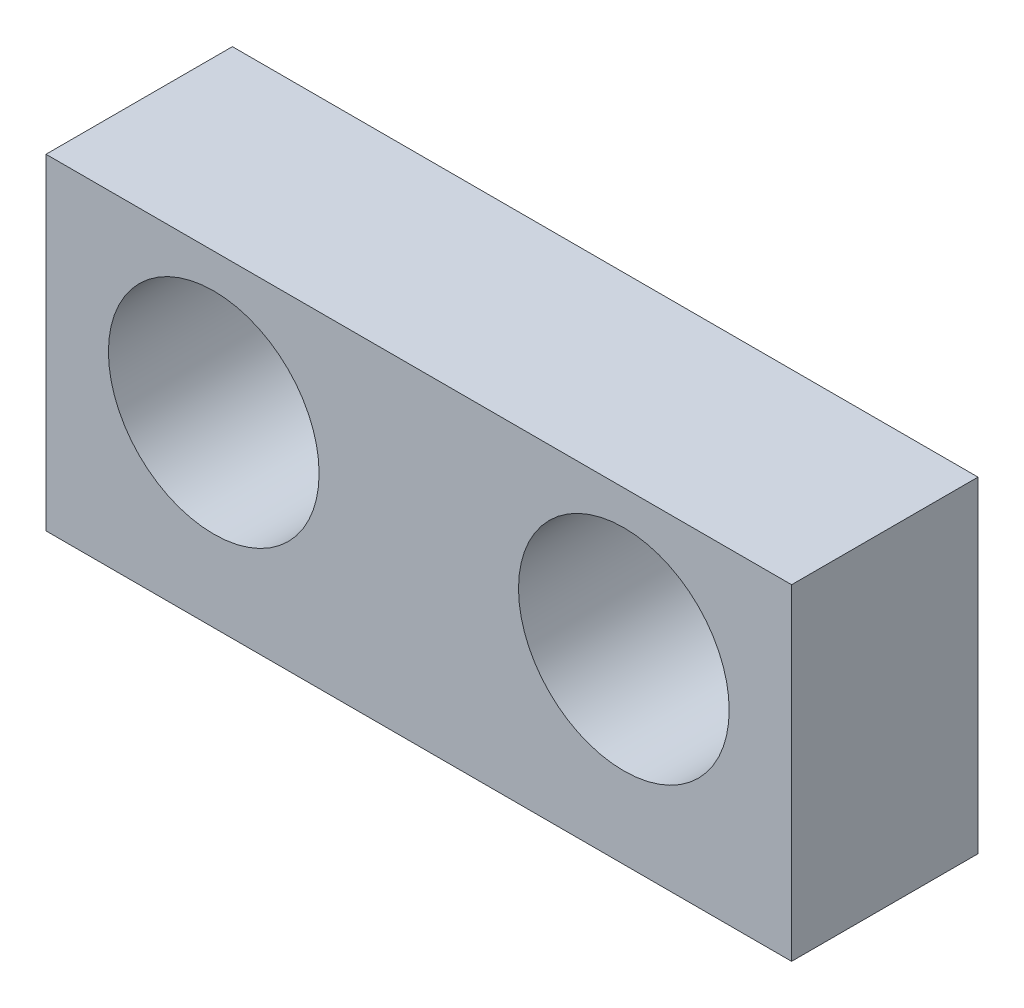
from build123d import *

# Parameters (mm, degrees)
SKETCH1_W      = 8
SKETCH1_H      = 3.5
EXTRUDE1_DEPTH = 2
SKETCH2_R      = 1.1303
EXTRUDE2_DEPTH = 3


with BuildPart() as part:
    # Sketch1 → Extrude1 (new body)
    with BuildSketch(Plane.XY):
        with Locations((0, 1.25)):
            Rectangle(SKETCH1_W, SKETCH1_H)
    extrude(amount=-EXTRUDE1_DEPTH)

    # Sketch2 → Extrude2 (cut, through all)
    with BuildSketch(Plane.XY):
        with Locations((-2.2, 1.5)):
            Circle(SKETCH2_R)
        with Locations((2.2, 1.5)):
            Circle(SKETCH2_R)
    extrude(amount=-EXTRUDE2_DEPTH, mode=Mode.SUBTRACT)


solid = part.part
